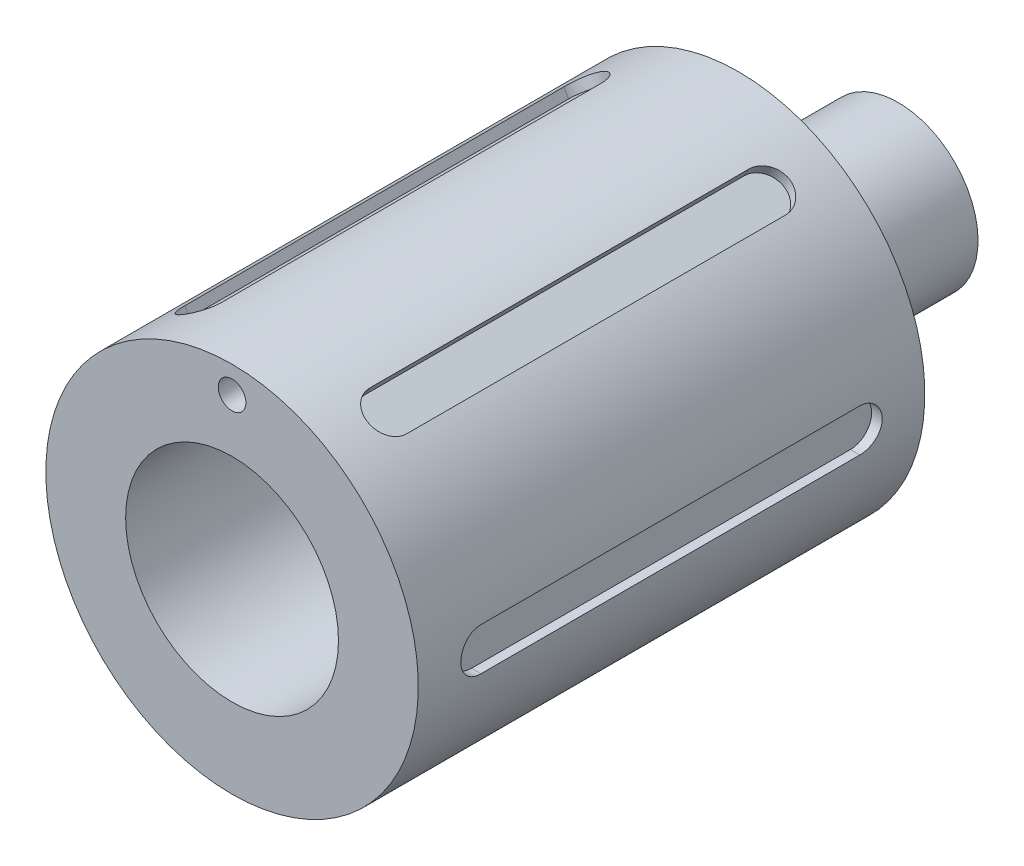
from build123d import *

# Parameters (mm, degrees)
CUT_EXTRUDE1_DEPTH              = 1.27
CIRPATTERN1_COUNT               = 6
F_1_8_0_13_DIAMETER_HOLE1_D     = 3.302
F_1_8_0_13_DIAMETER_HOLE1_DEPTH = 15.875
F_1_8_0_13_DIAMETER_HOLE1_TIP   = 0.992020882


with BuildPart() as part:
    # Sketch1 → Revolve1 (revolve)
    with BuildSketch(Plane(origin=(0, 0, 0), x_dir=(0, 0, -1), z_dir=(1, 0, 0))):
        Polygon((0, 22.225), (60.452, 22.225), (60.452, 9.525), (79.502, 9.525), (79.502, 0), (57.15, 0), (57.15, 12.7), (0, 12.7), align=None)
    revolve(axis=Axis((0, 0, 0), (0, 0, -1)))

    # Sketch2 → Cut-Extrude1 (cut)
    with BuildSketch(Plane(origin=(22.225, 0, 0), x_dir=(0, 0, -1), z_dir=(1, 0, 0))):
        with BuildLine():
            Line((7.62, 2.54), (52.832, 2.54))
            ThreePointArc((52.832, 2.54), (55.372, 0), (52.832, -2.54))
            Line((52.832, -2.54), (7.62, -2.54))
            ThreePointArc((7.62, -2.54), (5.08, 0), (7.62, 2.54))
        make_face()
    cut_extrude1 = extrude(amount=-CUT_EXTRUDE1_DEPTH, mode=Mode.SUBTRACT)

    # CirPattern1: Cut-Extrude1 ×6 about axis
    cirpattern1_axis = Axis((0, 0, 0), (0, 0, 1))
    for i in range(1, CIRPATTERN1_COUNT):
        add(cut_extrude1.rotate(cirpattern1_axis, i * 360 / CIRPATTERN1_COUNT), mode=Mode.SUBTRACT)

    # 1/8 (0.13) Diameter Hole1
    with Locations(Plane.XY):
        with Locations((0, 19.05)):
            Hole(F_1_8_0_13_DIAMETER_HOLE1_D / 2, depth=F_1_8_0_13_DIAMETER_HOLE1_DEPTH)
            with Locations((0, 0, -(F_1_8_0_13_DIAMETER_HOLE1_DEPTH + F_1_8_0_13_DIAMETER_HOLE1_TIP / 2))):  # 118° drill point
                Cone(0, F_1_8_0_13_DIAMETER_HOLE1_D / 2, F_1_8_0_13_DIAMETER_HOLE1_TIP, mode=Mode.SUBTRACT)


solid = part.part
